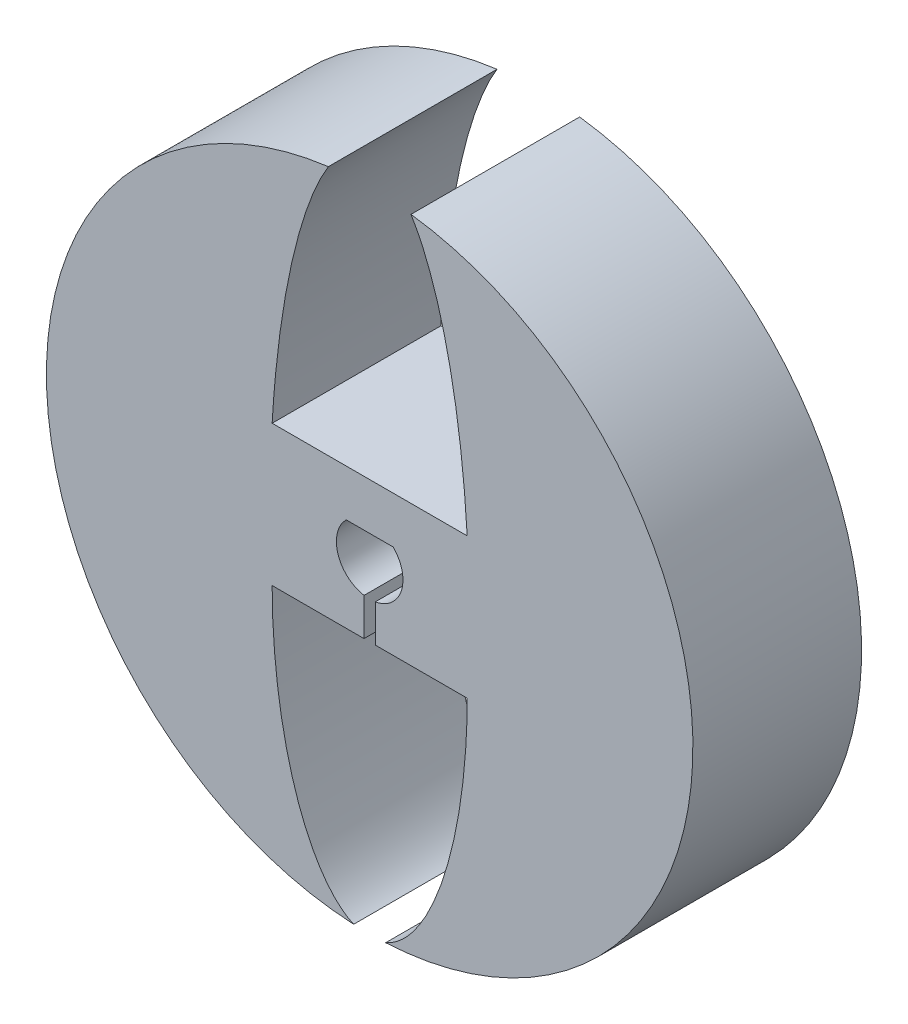
from build123d import *

# Parameters (mm, degrees)
SKETCH1_R           = 23
BOSS_EXTRUDE1_DEPTH = 12
CUT_EXTRUDE1_DEPTH  = 13


with BuildPart() as part:
    # Sketch1 → Boss-Extrude1 (new body)
    with BuildSketch(Plane.XY):
        Circle(SKETCH1_R)
    extrude(amount=BOSS_EXTRUDE1_DEPTH)

    # Sketch2 → Cut-Extrude1 (cut, through all)
    with BuildSketch(Plane.XY.offset(12)):
        with BuildLine():
            Line((-1.669663439, 1.682), (1.669663439, 1.682))
            ThreePointArc((1.669663439, 1.682), (2.259858272, -0.714101248), (0.4, -2.336000856))
            Line((0.4, -2.336000856), (0.4, -5))
            Line((0.4, -5), (6.939400576, -5))
            add(Edge.make_bspline(
                [(-6.939400576, -5), (-6.939400576, -23.218031299), (0, -23.218031299), (6.939400576, -23.218031299), (6.939400576, -5)],
                knots=[1.570796327, 1.570796327, 1.570796327, 3.141592654, 3.141592654, 4.71238898, 4.71238898, 4.71238898], degree=2, weights=[1, 0.707106781, 1, 0.707106781, 1]))
            Line((-6.939400576, -5), (-0.4, -5))
            Line((-0.4, -5), (-0.4, -2.336000856))
            ThreePointArc((-0.4, -2.336000856), (-2.259858272, -0.714101248), (-1.669663439, 1.682))
        make_face()
        with BuildLine():
            Line((-6.939400576, 5), (6.939400576, 5))
            add(Edge.make_bspline(
                [(6.939400576, 5), (5.785687162, 25.074195607), (0, 25.074195607), (-5.785687162, 25.074195607), (-6.939400576, 5)],
                knots=[4.913142926, 4.913142926, 4.913142926, 6.283185307, 6.283185307, 7.653227688, 7.653227688, 7.653227688], degree=2, weights=[1, 0.77440564, 1, 0.77440564, 1]))
        make_face()
    extrude(amount=-CUT_EXTRUDE1_DEPTH, mode=Mode.SUBTRACT)


solid = part.part
